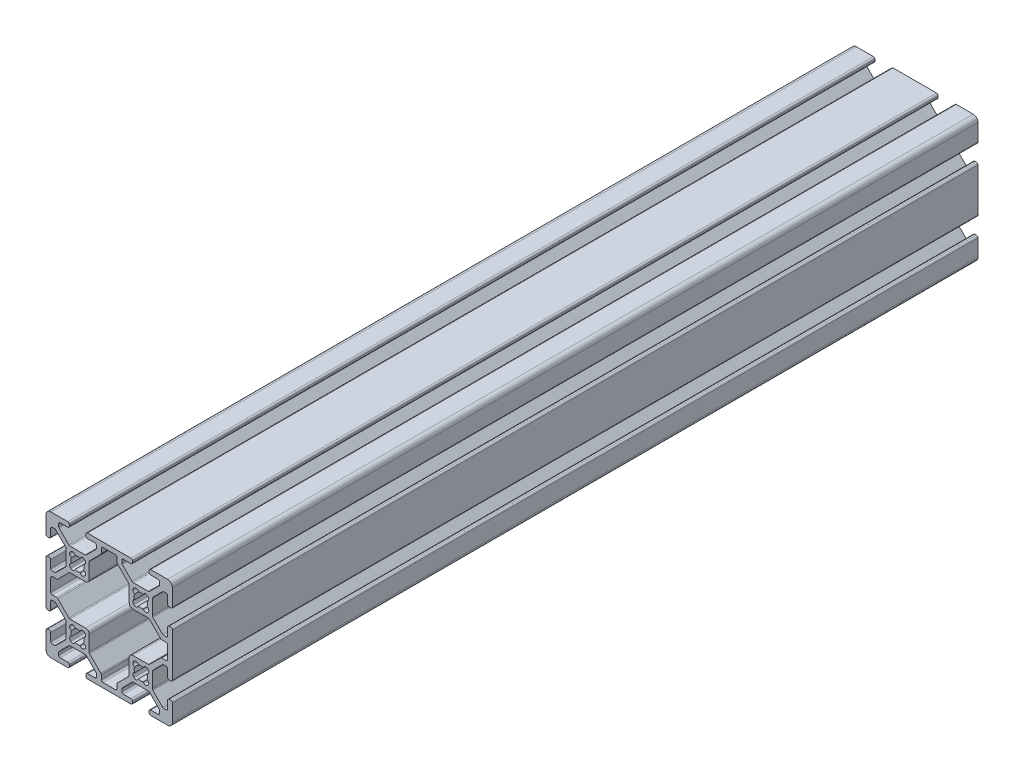
from build123d import *

# Parameters (mm, degrees)
EXTRUDE1_DEPTH = 255


with BuildPart() as part:
    # Sketch1 → Extrude1 (new body)
    with BuildSketch(Plane.XY):
        with BuildLine():
            Line((-22.383919339, -3.655), (-17.616080661, -3.655))
            ThreePointArc((-17.616080661, -3.655), (-17.421677478, -3.693669197), (-17.256870417, -3.803789755))
            Line((-17.256870417, -3.803789755), (-14.153789755, -6.906870417))
            ThreePointArc((-14.153789755, -6.906870417), (-14.043669197, -7.071677478), (-14.005, -7.266080661))
            Line((-14.005, -7.266080661), (-14.005, -7.992))
            ThreePointArc((-14.005, -7.992), (-14.153789755, -8.351210245), (-14.513, -8.5))
            Line((-14.513, -8.5), (-16.862, -8.5))
            ThreePointArc((-16.862, -8.5), (-17.221210245, -8.648789755), (-17.37, -9.008))
            Line((-17.37, -9.008), (-17.37, -9.492))
            ThreePointArc((-17.37, -9.492), (-17.221210245, -9.851210245), (-16.862, -10))
            Line((-16.862, -10), (-3.138, -10))
            ThreePointArc((-3.138, -10), (-2.778789755, -9.851210245), (-2.63, -9.492))
            Line((-2.63, -9.492), (-2.63, -9.008))
            ThreePointArc((-2.63, -9.008), (-2.778789755, -8.648789755), (-3.138, -8.5))
            Line((-3.138, -8.5), (-5.487, -8.5))
            ThreePointArc((-5.487, -8.5), (-5.846210245, -8.351210245), (-5.995, -7.992))
            Line((-5.995, -7.992), (-5.995, -7.266080661))
            ThreePointArc((-5.995, -7.266080661), (-5.956330803, -7.071677478), (-5.846210245, -6.906870417))
            Line((-5.846210245, -6.906870417), (-2.743129583, -3.803789755))
            ThreePointArc((-2.743129583, -3.803789755), (-2.578322522, -3.693669197), (-2.383919339, -3.655))
            Line((-2.383919339, -3.655), (2.383919339, -3.655))
            ThreePointArc((2.383919339, -3.655), (2.578322522, -3.693669197), (2.743129583, -3.803789755))
            Line((2.743129583, -3.803789755), (5.846210245, -6.906870417))
            ThreePointArc((5.846210245, -6.906870417), (5.956330803, -7.071677478), (5.995, -7.266080661))
            Line((5.995, -7.266080661), (5.995, -7.992))
            ThreePointArc((5.995, -7.992), (5.846210245, -8.351210245), (5.487, -8.5))
            Line((5.487, -8.5), (3.138, -8.5))
            ThreePointArc((3.138, -8.5), (2.778789755, -8.648789755), (2.63, -9.008))
            Line((2.63, -9.008), (2.63, -9.492))
            ThreePointArc((2.63, -9.492), (2.778789755, -9.851210245), (3.138, -10))
            Line((3.138, -10), (8.5, -10))
            ThreePointArc((8.5, -10), (9.560660172, -9.560660172), (10, -8.5))
            Line((10, -8.5), (10, -3.138))
            ThreePointArc((10, -3.138), (9.851210245, -2.778789755), (9.492, -2.63))
            Line((9.492, -2.63), (9.008, -2.63))
            ThreePointArc((9.008, -2.63), (8.648789755, -2.778789755), (8.5, -3.138))
            Line((8.5, -3.138), (8.5, -5.487))
            ThreePointArc((8.5, -5.487), (8.351210245, -5.846210245), (7.992, -5.995))
            Line((7.992, -5.995), (7.266080661, -5.995))
            ThreePointArc((7.266080661, -5.995), (7.071677478, -5.956330803), (6.906870417, -5.846210245))
            Line((6.906870417, -5.846210245), (3.803789755, -2.743129583))
            ThreePointArc((3.803789755, -2.743129583), (3.693669197, -2.578322522), (3.655, -2.383919339))
            Line((3.655, -2.383919339), (3.655, 2.383919339))
            ThreePointArc((3.655, 2.383919339), (3.693669197, 2.578322522), (3.803789755, 2.743129583))
            Line((3.803789755, 2.743129583), (6.906870417, 5.846210245))
            ThreePointArc((6.906870417, 5.846210245), (7.071677478, 5.956330803), (7.266080661, 5.995))
            Line((7.266080661, 5.995), (7.992, 5.995))
            ThreePointArc((7.992, 5.995), (8.351210245, 5.846210245), (8.5, 5.487))
            Line((8.5, 5.487), (8.5, 3.138))
            ThreePointArc((8.5, 3.138), (8.648789755, 2.778789755), (9.008, 2.63))
            Line((9.008, 2.63), (9.492, 2.63))
            ThreePointArc((9.492, 2.63), (9.851210245, 2.778789755), (10, 3.138))
            Line((10, 3.138), (10, 16.862))
            ThreePointArc((10, 16.862), (9.851210245, 17.221210245), (9.492, 17.37))
            Line((9.492, 17.37), (9.008, 17.37))
            ThreePointArc((9.008, 17.37), (8.648789755, 17.221210245), (8.5, 16.862))
            Line((8.5, 16.862), (8.5, 14.513))
            ThreePointArc((8.5, 14.513), (8.351210245, 14.153789755), (7.992, 14.005))
            Line((7.992, 14.005), (7.266080661, 14.005))
            ThreePointArc((7.266080661, 14.005), (7.071677478, 14.043669197), (6.906870417, 14.153789755))
            Line((6.906870417, 14.153789755), (3.803789755, 17.256870417))
            ThreePointArc((3.803789755, 17.256870417), (3.693669197, 17.421677478), (3.655, 17.616080661))
            Line((3.655, 17.616080661), (3.655, 22.383919339))
            ThreePointArc((3.655, 22.383919339), (3.693669197, 22.578322522), (3.803789755, 22.743129583))
            Line((3.803789755, 22.743129583), (6.906870417, 25.846210245))
            ThreePointArc((6.906870417, 25.846210245), (7.071677478, 25.956330803), (7.266080661, 25.995))
            Line((7.266080661, 25.995), (7.992, 25.995))
            ThreePointArc((7.992, 25.995), (8.351210245, 25.846210245), (8.5, 25.487))
            Line((8.5, 25.487), (8.5, 23.138))
            ThreePointArc((8.5, 23.138), (8.648789755, 22.778789755), (9.008, 22.63))
            Line((9.008, 22.63), (9.492, 22.63))
            ThreePointArc((9.492, 22.63), (9.851210245, 22.778789755), (10, 23.138))
            Line((10, 23.138), (10, 28.5))
            ThreePointArc((10, 28.5), (9.560660172, 29.560660172), (8.5, 30))
            Line((8.5, 30), (3.138, 30))
            ThreePointArc((3.138, 30), (2.778789755, 29.851210245), (2.63, 29.492))
            Line((2.63, 29.492), (2.63, 29.008))
            ThreePointArc((2.63, 29.008), (2.778789755, 28.648789755), (3.138, 28.5))
            Line((3.138, 28.5), (5.487, 28.5))
            ThreePointArc((5.487, 28.5), (5.846210245, 28.351210245), (5.995, 27.992))
            Line((5.995, 27.992), (5.995, 27.266080661))
            ThreePointArc((5.995, 27.266080661), (5.956330803, 27.071677478), (5.846210245, 26.906870417))
            Line((5.846210245, 26.906870417), (2.743129583, 23.803789755))
            ThreePointArc((2.743129583, 23.803789755), (2.578322522, 23.693669197), (2.383919339, 23.655))
            Line((2.383919339, 23.655), (-2.383919339, 23.655))
            ThreePointArc((-2.383919339, 23.655), (-2.578322522, 23.693669197), (-2.743129583, 23.803789755))
            Line((-2.743129583, 23.803789755), (-5.846210245, 26.906870417))
            ThreePointArc((-5.846210245, 26.906870417), (-5.956330803, 27.071677478), (-5.995, 27.266080661))
            Line((-5.995, 27.266080661), (-5.995, 27.992))
            ThreePointArc((-5.995, 27.992), (-5.846210245, 28.351210245), (-5.487, 28.5))
            Line((-5.487, 28.5), (-3.138, 28.5))
            ThreePointArc((-3.138, 28.5), (-2.778789755, 28.648789755), (-2.63, 29.008))
            Line((-2.63, 29.008), (-2.63, 29.492))
            ThreePointArc((-2.63, 29.492), (-2.778789755, 29.851210245), (-3.138, 30))
            Line((-3.138, 30), (-16.862, 30))
            ThreePointArc((-16.862, 30), (-17.221210245, 29.851210245), (-17.37, 29.492))
            Line((-17.37, 29.492), (-17.37, 29.008))
            ThreePointArc((-17.37, 29.008), (-17.221210245, 28.648789755), (-16.862, 28.5))
            Line((-16.862, 28.5), (-14.513, 28.5))
            ThreePointArc((-14.513, 28.5), (-14.153789755, 28.351210245), (-14.005, 27.992))
            Line((-14.005, 27.992), (-14.005, 27.266080661))
            ThreePointArc((-14.005, 27.266080661), (-14.043669197, 27.071677478), (-14.153789755, 26.906870417))
            Line((-14.153789755, 26.906870417), (-17.256870417, 23.803789755))
            ThreePointArc((-17.256870417, 23.803789755), (-17.421677478, 23.693669197), (-17.616080661, 23.655))
            Line((-17.616080661, 23.655), (-22.383919339, 23.655))
            ThreePointArc((-22.383919339, 23.655), (-22.578322522, 23.693669197), (-22.743129583, 23.803789755))
            Line((-22.743129583, 23.803789755), (-25.846210245, 26.906870417))
            ThreePointArc((-25.846210245, 26.906870417), (-25.956330803, 27.071677478), (-25.995, 27.266080661))
            Line((-25.995, 27.266080661), (-25.995, 27.992))
            ThreePointArc((-25.995, 27.992), (-25.846210245, 28.351210245), (-25.487, 28.5))
            Line((-25.487, 28.5), (-23.138, 28.5))
            ThreePointArc((-23.138, 28.5), (-22.778789755, 28.648789755), (-22.63, 29.008))
            Line((-22.63, 29.008), (-22.63, 29.492))
            ThreePointArc((-22.63, 29.492), (-22.778789755, 29.851210245), (-23.138, 30))
            Line((-23.138, 30), (-28.5, 30))
            ThreePointArc((-28.5, 30), (-29.560660172, 29.560660172), (-30, 28.5))
            Line((-30, 28.5), (-30, 23.138))
            ThreePointArc((-30, 23.138), (-29.851210245, 22.778789755), (-29.492, 22.63))
            Line((-29.492, 22.63), (-29.008, 22.63))
            ThreePointArc((-29.008, 22.63), (-28.648789755, 22.778789755), (-28.5, 23.138))
            Line((-28.5, 23.138), (-28.5, 25.487))
            ThreePointArc((-28.5, 25.487), (-28.351210245, 25.846210245), (-27.992, 25.995))
            Line((-27.992, 25.995), (-27.266080661, 25.995))
            ThreePointArc((-27.266080661, 25.995), (-27.071677478, 25.956330803), (-26.906870417, 25.846210245))
            Line((-26.906870417, 25.846210245), (-23.803789755, 22.743129583))
            ThreePointArc((-23.803789755, 22.743129583), (-23.693669197, 22.578322522), (-23.655, 22.383919339))
            Line((-23.655, 22.383919339), (-23.655, 17.616080661))
            ThreePointArc((-23.655, 17.616080661), (-23.693669197, 17.421677478), (-23.803789755, 17.256870417))
            Line((-23.803789755, 17.256870417), (-26.906870417, 14.153789755))
            ThreePointArc((-26.906870417, 14.153789755), (-27.071677478, 14.043669197), (-27.266080661, 14.005))
            Line((-27.266080661, 14.005), (-27.992, 14.005))
            ThreePointArc((-27.992, 14.005), (-28.351210245, 14.153789755), (-28.5, 14.513))
            Line((-28.5, 14.513), (-28.5, 16.862))
            ThreePointArc((-28.5, 16.862), (-28.648789755, 17.221210245), (-29.008, 17.37))
            Line((-29.008, 17.37), (-29.492, 17.37))
            ThreePointArc((-29.492, 17.37), (-29.851210245, 17.221210245), (-30, 16.862))
            Line((-30, 16.862), (-30, 3.138))
            ThreePointArc((-30, 3.138), (-29.851210245, 2.778789755), (-29.492, 2.63))
            Line((-29.492, 2.63), (-29.008, 2.63))
            ThreePointArc((-29.008, 2.63), (-28.648789755, 2.778789755), (-28.5, 3.138))
            Line((-28.5, 3.138), (-28.5, 5.487))
            ThreePointArc((-28.5, 5.487), (-28.351210245, 5.846210245), (-27.992, 5.995))
            Line((-27.992, 5.995), (-27.266080661, 5.995))
            ThreePointArc((-27.266080661, 5.995), (-27.071677478, 5.956330803), (-26.906870417, 5.846210245))
            Line((-26.906870417, 5.846210245), (-23.803789755, 2.743129583))
            ThreePointArc((-23.803789755, 2.743129583), (-23.693669197, 2.578322522), (-23.655, 2.383919339))
            Line((-23.655, 2.383919339), (-23.655, -2.383919339))
            ThreePointArc((-23.655, -2.383919339), (-23.693669197, -2.578322522), (-23.803789755, -2.743129583))
            Line((-23.803789755, -2.743129583), (-26.906870417, -5.846210245))
            ThreePointArc((-26.906870417, -5.846210245), (-27.071677478, -5.956330803), (-27.266080661, -5.995))
            Line((-27.266080661, -5.995), (-27.992, -5.995))
            ThreePointArc((-27.992, -5.995), (-28.351210245, -5.846210245), (-28.5, -5.487))
            Line((-28.5, -5.487), (-28.5, -3.138))
            ThreePointArc((-28.5, -3.138), (-28.648789755, -2.778789755), (-29.008, -2.63))
            Line((-29.008, -2.63), (-29.492, -2.63))
            ThreePointArc((-29.492, -2.63), (-29.851210245, -2.778789755), (-30, -3.138))
            Line((-30, -3.138), (-30, -8.5))
            ThreePointArc((-30, -8.5), (-29.560660172, -9.560660172), (-28.5, -10))
            Line((-28.5, -10), (-23.138, -10))
            ThreePointArc((-23.138, -10), (-22.778789755, -9.851210245), (-22.63, -9.492))
            Line((-22.63, -9.492), (-22.63, -9.008))
            ThreePointArc((-22.63, -9.008), (-22.778789755, -8.648789755), (-23.138, -8.5))
            Line((-23.138, -8.5), (-25.487, -8.5))
            ThreePointArc((-25.487, -8.5), (-25.846210245, -8.351210245), (-25.995, -7.992))
            Line((-25.995, -7.992), (-25.995, -7.266080661))
            ThreePointArc((-25.995, -7.266080661), (-25.956330803, -7.071677478), (-25.846210245, -6.906870417))
            Line((-25.846210245, -6.906870417), (-22.743129583, -3.803789755))
            ThreePointArc((-22.743129583, -3.803789755), (-22.578322522, -3.693669197), (-22.383919339, -3.655))
        make_face()
        with BuildLine():
            Line((-2.124900844, 17.695494034), (-2.304505966, 17.875099156))
            ThreePointArc((-2.304505966, 17.875099156), (-2.505938017, 18.643532189), (-1.935133506, 19.196023282))
            ThreePointArc((-1.935133506, 19.196023282), (-2.0955, 20), (-1.935133506, 20.803976718))
            ThreePointArc((-1.935133506, 20.803976718), (-2.505938017, 21.356467811), (-2.304505966, 22.124900844))
            Line((-2.304505966, 22.124900844), (-2.124900844, 22.304505966))
            ThreePointArc((-2.124900844, 22.304505966), (-1.356467811, 22.505938017), (-0.803976718, 21.935133506))
            ThreePointArc((-0.803976718, 21.935133506), (0, 22.0955), (0.803976718, 21.935133506))
            ThreePointArc((0.803976718, 21.935133506), (1.356467811, 22.505938017), (2.124900844, 22.304505966))
            Line((2.124900844, 22.304505966), (2.304505966, 22.124900844))
            ThreePointArc((2.304505966, 22.124900844), (2.505938017, 21.356467811), (1.935133506, 20.803976718))
            ThreePointArc((1.935133506, 20.803976718), (2.0955, 20), (1.935133506, 19.196023282))
            ThreePointArc((1.935133506, 19.196023282), (2.505938017, 18.643532189), (2.304505966, 17.875099156))
            Line((2.304505966, 17.875099156), (2.124900844, 17.695494034))
            ThreePointArc((2.124900844, 17.695494034), (1.356467811, 17.494061983), (0.803976718, 18.064866494))
            ThreePointArc((0.803976718, 18.064866494), (0, 17.9045), (-0.803976718, 18.064866494))
            ThreePointArc((-0.803976718, 18.064866494), (-1.356467811, 17.494061983), (-2.124900844, 17.695494034))
        make_face(mode=Mode.SUBTRACT)
        with BuildLine():
            Line((-22.124900844, 17.695494034), (-22.304505966, 17.875099156))
            ThreePointArc((-22.304505966, 17.875099156), (-22.505938017, 18.643532189), (-21.935133506, 19.196023282))
            ThreePointArc((-21.935133506, 19.196023282), (-22.0955, 20), (-21.935133506, 20.803976718))
            ThreePointArc((-21.935133506, 20.803976718), (-22.505938017, 21.356467811), (-22.304505966, 22.124900844))
            Line((-22.304505966, 22.124900844), (-22.124900844, 22.304505966))
            ThreePointArc((-22.124900844, 22.304505966), (-21.356467811, 22.505938017), (-20.803976718, 21.935133506))
            ThreePointArc((-20.803976718, 21.935133506), (-20, 22.0955), (-19.196023282, 21.935133506))
            ThreePointArc((-19.196023282, 21.935133506), (-18.643532189, 22.505938017), (-17.875099156, 22.304505966))
            Line((-17.875099156, 22.304505966), (-17.695494034, 22.124900844))
            ThreePointArc((-17.695494034, 22.124900844), (-17.494061983, 21.356467811), (-18.064866494, 20.803976718))
            ThreePointArc((-18.064866494, 20.803976718), (-17.9045, 20), (-18.064866494, 19.196023282))
            ThreePointArc((-18.064866494, 19.196023282), (-17.494061983, 18.643532189), (-17.695494034, 17.875099156))
            Line((-17.695494034, 17.875099156), (-17.875099156, 17.695494034))
            ThreePointArc((-17.875099156, 17.695494034), (-18.643532189, 17.494061983), (-19.196023282, 18.064866494))
            ThreePointArc((-19.196023282, 18.064866494), (-20, 17.9045), (-20.803976718, 18.064866494))
            ThreePointArc((-20.803976718, 18.064866494), (-21.356467811, 17.494061983), (-22.124900844, 17.695494034))
        make_face(mode=Mode.SUBTRACT)
        with BuildLine():
            Line((-2.124900844, -2.304505966), (-2.304505966, -2.124900844))
            ThreePointArc((-2.304505966, -2.124900844), (-2.505938017, -1.356467811), (-1.935133506, -0.803976718))
            ThreePointArc((-1.935133506, -0.803976718), (-2.0955, 0), (-1.935133506, 0.803976718))
            ThreePointArc((-1.935133506, 0.803976718), (-2.505938017, 1.356467811), (-2.304505966, 2.124900844))
            Line((-2.304505966, 2.124900844), (-2.124900844, 2.304505966))
            ThreePointArc((-2.124900844, 2.304505966), (-1.356467811, 2.505938017), (-0.803976718, 1.935133506))
            ThreePointArc((-0.803976718, 1.935133506), (0, 2.0955), (0.803976718, 1.935133506))
            ThreePointArc((0.803976718, 1.935133506), (1.356467811, 2.505938017), (2.124900844, 2.304505966))
            Line((2.124900844, 2.304505966), (2.304505966, 2.124900844))
            ThreePointArc((2.304505966, 2.124900844), (2.505938017, 1.356467811), (1.935133506, 0.803976718))
            ThreePointArc((1.935133506, 0.803976718), (2.0955, 0), (1.935133506, -0.803976718))
            ThreePointArc((1.935133506, -0.803976718), (2.505938017, -1.356467811), (2.304505966, -2.124900844))
            Line((2.304505966, -2.124900844), (2.124900844, -2.304505966))
            ThreePointArc((2.124900844, -2.304505966), (1.356467811, -2.505938017), (0.803976718, -1.935133506))
            ThreePointArc((0.803976718, -1.935133506), (0, -2.0955), (-0.803976718, -1.935133506))
            ThreePointArc((-0.803976718, -1.935133506), (-1.356467811, -2.505938017), (-2.124900844, -2.304505966))
        make_face(mode=Mode.SUBTRACT)
        with BuildLine():
            Line((-12.505, -7.992), (-12.505, -6.644760318))
            ThreePointArc((-12.505, -6.644760318), (-12.543669197, -6.450357134), (-12.653789755, -6.285550073))
            Line((-12.653789755, -6.285550073), (-16.196210245, -2.743129583))
            ThreePointArc((-16.196210245, -2.743129583), (-16.306330803, -2.578322522), (-16.345, -2.383919339))
            Line((-16.345, -2.383919339), (-16.345, 2.512))
            ThreePointArc((-16.345, 2.512), (-16.679776949, 3.320223051), (-17.488, 3.655))
            Line((-17.488, 3.655), (-22.383919339, 3.655))
            ThreePointArc((-22.383919339, 3.655), (-22.578322522, 3.693669197), (-22.743129583, 3.803789755))
            Line((-22.743129583, 3.803789755), (-26.285550073, 7.346210245))
            ThreePointArc((-26.285550073, 7.346210245), (-26.450357134, 7.456330803), (-26.644760318, 7.495))
            Line((-26.644760318, 7.495), (-27.992, 7.495))
            ThreePointArc((-27.992, 7.495), (-28.351210245, 7.643789755), (-28.5, 8.003))
            Line((-28.5, 8.003), (-28.5, 11.997))
            ThreePointArc((-28.5, 11.997), (-28.351210245, 12.356210245), (-27.992, 12.505))
            Line((-27.992, 12.505), (-26.644760318, 12.505))
            ThreePointArc((-26.644760318, 12.505), (-26.450357134, 12.543669197), (-26.285550073, 12.653789755))
            Line((-26.285550073, 12.653789755), (-22.743129583, 16.196210245))
            ThreePointArc((-22.743129583, 16.196210245), (-22.578322522, 16.306330803), (-22.383919339, 16.345))
            Line((-22.383919339, 16.345), (-17.488, 16.345))
            ThreePointArc((-17.488, 16.345), (-16.679776949, 16.679776949), (-16.345, 17.488))
            Line((-16.345, 17.488), (-16.345, 22.383919339))
            ThreePointArc((-16.345, 22.383919339), (-16.306330803, 22.578322522), (-16.196210245, 22.743129583))
            Line((-16.196210245, 22.743129583), (-12.653789755, 26.285550073))
            ThreePointArc((-12.653789755, 26.285550073), (-12.543669197, 26.450357134), (-12.505, 26.644760318))
            Line((-12.505, 26.644760318), (-12.505, 27.992))
            ThreePointArc((-12.505, 27.992), (-12.356210245, 28.351210245), (-11.997, 28.5))
            Line((-11.997, 28.5), (-8.003, 28.5))
            ThreePointArc((-8.003, 28.5), (-7.643789755, 28.351210245), (-7.495, 27.992))
            Line((-7.495, 27.992), (-7.495, 26.644760318))
            ThreePointArc((-7.495, 26.644760318), (-7.456330803, 26.450357134), (-7.346210245, 26.285550073))
            Line((-7.346210245, 26.285550073), (-3.803789755, 22.743129583))
            ThreePointArc((-3.803789755, 22.743129583), (-3.693669197, 22.578322522), (-3.655, 22.383919339))
            Line((-3.655, 22.383919339), (-3.655, 17.488))
            ThreePointArc((-3.655, 17.488), (-3.320223051, 16.679776949), (-2.512, 16.345))
            Line((-2.512, 16.345), (2.383919339, 16.345))
            ThreePointArc((2.383919339, 16.345), (2.578322522, 16.306330803), (2.743129583, 16.196210245))
            Line((2.743129583, 16.196210245), (6.285550073, 12.653789755))
            ThreePointArc((6.285550073, 12.653789755), (6.450357134, 12.543669197), (6.644760318, 12.505))
            Line((6.644760318, 12.505), (7.992, 12.505))
            ThreePointArc((7.992, 12.505), (8.351210245, 12.356210245), (8.5, 11.997))
            Line((8.5, 11.997), (8.5, 8.003))
            ThreePointArc((8.5, 8.003), (8.351210245, 7.643789755), (7.992, 7.495))
            Line((7.992, 7.495), (6.644760318, 7.495))
            ThreePointArc((6.644760318, 7.495), (6.450357134, 7.456330803), (6.285550073, 7.346210245))
            Line((6.285550073, 7.346210245), (2.743129583, 3.803789755))
            ThreePointArc((2.743129583, 3.803789755), (2.578322522, 3.693669197), (2.383919339, 3.655))
            Line((2.383919339, 3.655), (-2.512, 3.655))
            ThreePointArc((-2.512, 3.655), (-3.320223051, 3.320223051), (-3.655, 2.512))
            Line((-3.655, 2.512), (-3.655, -2.383919339))
            ThreePointArc((-3.655, -2.383919339), (-3.693669197, -2.578322522), (-3.803789755, -2.743129583))
            Line((-3.803789755, -2.743129583), (-7.346210245, -6.285550073))
            ThreePointArc((-7.346210245, -6.285550073), (-7.456330803, -6.450357134), (-7.495, -6.644760318))
            Line((-7.495, -6.644760318), (-7.495, -7.992))
            ThreePointArc((-7.495, -7.992), (-7.643789755, -8.351210245), (-8.003, -8.5))
            Line((-8.003, -8.5), (-11.997, -8.5))
            ThreePointArc((-11.997, -8.5), (-12.356210245, -8.351210245), (-12.505, -7.992))
        make_face(mode=Mode.SUBTRACT)
        with BuildLine():
            Line((-22.124900844, -2.304505966), (-22.304505966, -2.124900844))
            ThreePointArc((-22.304505966, -2.124900844), (-22.505938017, -1.356467811), (-21.935133506, -0.803976718))
            ThreePointArc((-21.935133506, -0.803976718), (-22.0955, 0), (-21.935133506, 0.803976718))
            ThreePointArc((-21.935133506, 0.803976718), (-22.505938017, 1.356467811), (-22.304505966, 2.124900844))
            Line((-22.304505966, 2.124900844), (-22.124900844, 2.304505966))
            ThreePointArc((-22.124900844, 2.304505966), (-21.356467811, 2.505938017), (-20.803976718, 1.935133506))
            ThreePointArc((-20.803976718, 1.935133506), (-20, 2.0955), (-19.196023282, 1.935133506))
            ThreePointArc((-19.196023282, 1.935133506), (-18.643532189, 2.505938017), (-17.875099156, 2.304505966))
            Line((-17.875099156, 2.304505966), (-17.695494034, 2.124900844))
            ThreePointArc((-17.695494034, 2.124900844), (-17.494061983, 1.356467811), (-18.064866494, 0.803976718))
            ThreePointArc((-18.064866494, 0.803976718), (-17.9045, 0), (-18.064866494, -0.803976718))
            ThreePointArc((-18.064866494, -0.803976718), (-17.494061983, -1.356467811), (-17.695494034, -2.124900844))
            Line((-17.695494034, -2.124900844), (-17.875099156, -2.304505966))
            ThreePointArc((-17.875099156, -2.304505966), (-18.643532189, -2.505938017), (-19.196023282, -1.935133506))
            ThreePointArc((-19.196023282, -1.935133506), (-20, -2.0955), (-20.803976718, -1.935133506))
            ThreePointArc((-20.803976718, -1.935133506), (-21.356467811, -2.505938017), (-22.124900844, -2.304505966))
        make_face(mode=Mode.SUBTRACT)
    extrude(amount=-EXTRUDE1_DEPTH)


solid = part.part
